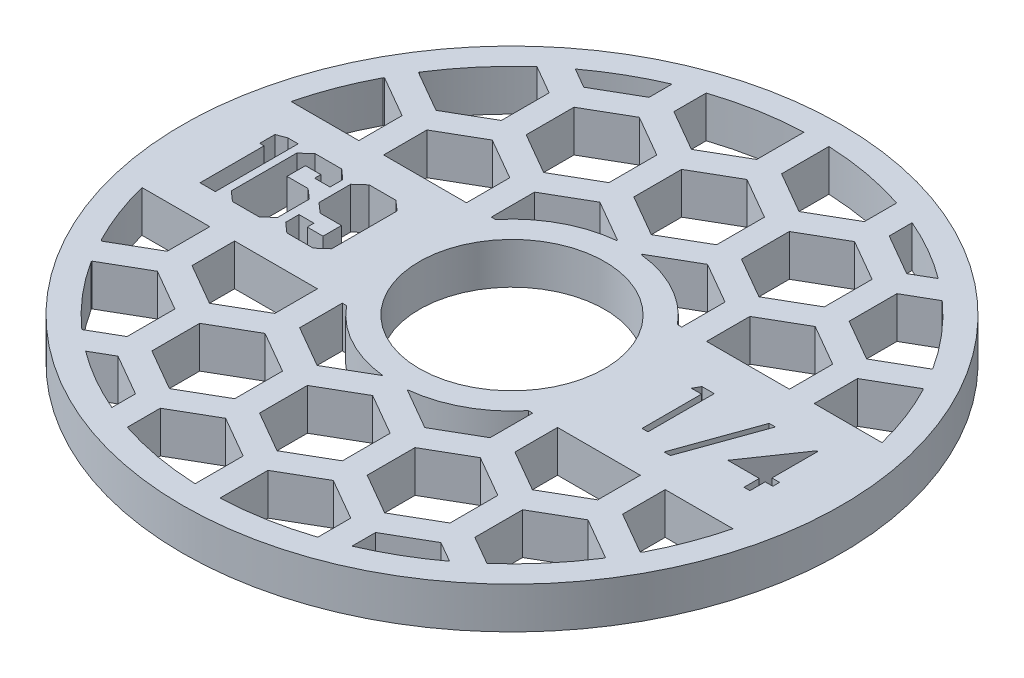
from build123d import *

# Parameters (mm, degrees)
SKETCH1_R               = 50.546
SKETCH1_R_2             = 14.224
BOSS_EXTRUDE1_DEPTH     = 6.35
CUT_EXTRUDE1_DEPTH      = 1
CUT_EXTRUDE1_DEPTH_BACK = 7.35
CUT_EXTRUDE2_DEPTH      = 1
CUT_EXTRUDE2_DEPTH_BACK = 7.35


with BuildPart() as part:
    # Sketch1 → Boss-Extrude1 (new body)
    with BuildSketch(Plane(origin=(0, 0, 0), x_dir=(1, 0, 0), z_dir=(0, 1, 0))):
        Circle(SKETCH1_R)
        Circle(SKETCH1_R_2, mode=Mode.SUBTRACT)
    extrude(amount=BOSS_EXTRUDE1_DEPTH)

    # Sketch2 → Cut-Extrude1 (cut, two sides)
    with BuildSketch(Plane(origin=(0, 6.35, 0), x_dir=(1, 0, 0), z_dir=(0, 1, 0))) as cut_extrude1_sk:
        Polygon((-22.636037344, -5.022991324), (-24.137904564, -6.35), (-28.181208978, -6.35), (-29.68547152, -5.022991324), (-29.68547152, -2.979781215), (-27.397938514, -2.979781215), (-27.397938514, -4.004979253), (-24.978662769, -4.004979253), (-24.978662769, -1.176103357), (-28.253068653, -1.176103357), (-29.750145228, 0.150905319), (-29.750145228, 5.015805356), (-28.253068653, 6.35), (-24.154671822, 6.35), (-22.636037344, 5.008619389), align=None)
        Polygon((-30.945411166, -5.022991324), (-32.449673708, -6.35), (-36.524117314, -6.35), (-38.028379857, -5.022991324), (-38.028379857, 5.015805356), (-36.540884572, 6.35), (-32.473626933, 6.35), (-30.969364391, 5.015805356), (-30.969364391, 3.05164089), (-33.321571105, 3.05164089), (-33.321571105, 4.004979253), (-35.68335911, 4.004979253), (-35.68335911, 1.176103357), (-32.449673708, 1.176103357), (-30.945411166, -0.141324029), align=None)
        Polygon((-39.151786118, -6.35), (-41.496806865, -6.35), (-41.496806865, 3.463636364), (-42.167497171, 3.463636364), (-42.167497171, 5.808657111), (-40.720722369, 6.35), (-39.151786118, 6.35), align=None)
        Polygon((24.058766026, 5.08), (25.937307692, 5.08), (25.937307692, -5.08), (25.025512821, -5.08), (25.025512821, 4.037948718), (23.462435897, 4.037948718), align=None)
        Polygon((35.05525641, 5.340512821), (30.805641026, -6.512820513), (29.845, -6.512820513), (34.094615385, 5.340512821), align=None)
        Polygon((41.38286859, 5.340512821), (41.568076923, 5.340512821), (41.568076923, -1.693333333), (42.740384615, -1.693333333), (42.740384615, -2.735384615), (41.568076923, -2.735384615), (41.568076923, -5.08), (40.656282051, -5.08), (40.656282051, -2.735384615), (35.836794872, -2.735384615), align=None)
    extrude(amount=CUT_EXTRUDE1_DEPTH, mode=Mode.SUBTRACT)
    extrude(cut_extrude1_sk.sketch, amount=-CUT_EXTRUDE1_DEPTH_BACK, mode=Mode.SUBTRACT)

    # Sketch3 → Cut-Extrude2 (cut, two sides)
    with BuildSketch(Plane(origin=(0, 6.35, 0), x_dir=(1, 0, 0), z_dir=(0, 1, 0))) as cut_extrude2_sk:
        with BuildLine():
            Line((-45.316760652, 11.43), (-34.925, 11.43))
            Line((-34.925, 11.43), (-34.925, 18.070094793))
            Line((-34.925, 18.070094793), (-41.275, 21.736269002))
            Line((-41.275, 21.736269002), (-41.416615017, 21.654507534))
            ThreePointArc((-41.416615017, 21.654507534), (-43.666975534, 16.656798723), (-45.316760652, 11.43))
        make_face()
        Polygon((-31.115, 11.43), (-18.415, 11.43), (-18.415, 18.070094793), (-24.765, 21.736269002), (-31.115, 18.070094793), align=None)
        with BuildLine():
            ThreePointArc((-31.072970625, 34.910230485), (-35.555600159, 30.332375333), (-39.37, 25.184455444))
            Line((-39.37, 25.184455444), (-39.37, 25.035825791))
            Line((-39.37, 25.035825791), (-33.02, 21.369651581))
            Line((-33.02, 21.369651581), (-26.67, 25.035825791))
            Line((-26.67, 25.035825791), (-26.67, 32.368174209))
            Line((-26.67, 32.368174209), (-31.072970625, 34.910230485))
        make_face()
        with BuildLine():
            ThreePointArc((-18.415, 42.955109952), (-23.281499402, 40.524381323), (-27.832591826, 37.544647132))
            Line((-27.832591826, 37.544647132), (-24.765, 35.773572165))
            Line((-24.765, 35.773572165), (-18.415, 39.439746374))
            Line((-18.415, 39.439746374), (-18.415, 42.955109952))
        make_face()
        Polygon((-22.86, 32.368174209), (-22.86, 25.035825791), (-16.51, 21.369651581), (-10.16, 25.035825791), (-10.16, 32.368174209), (-16.51, 36.034348419), align=None)
        with BuildLine():
            ThreePointArc((-1.905, 46.697159132), (-8.334842466, 45.986781765), (-14.605, 44.395356413))
            Line((-14.605, 44.395356413), (-14.605, 39.439746374))
            Line((-14.605, 39.439746374), (-8.255, 35.773572165))
            Line((-8.255, 35.773572165), (-1.905, 39.439746374))
            Line((-1.905, 39.439746374), (-1.905, 46.697159132))
        make_face()
        Polygon((-6.35, 32.368174209), (-6.35, 25.035825791), (0, 21.369651581), (6.35, 25.035825791), (6.35, 32.368174209), (0, 36.034348419), align=None)
        with BuildLine():
            Line((14.605, 39.439746374), (14.605, 44.395356413))
            ThreePointArc((14.605, 44.395356413), (8.334842466, 45.986781765), (1.905, 46.697159132))
            Line((1.905, 46.697159132), (1.905, 39.439746374))
            Line((1.905, 39.439746374), (8.255, 35.773572165))
            Line((8.255, 35.773572165), (14.605, 39.439746374))
        make_face()
        with BuildLine():
            Line((-14.605, 11.43), (-13.949202701, 11.43))
            ThreePointArc((-13.949202701, 11.43), (-8.568052185, 15.868636922), (-1.905, 17.933101544))
            Line((-1.905, 17.933101544), (-1.905, 18.070094793))
            Line((-1.905, 18.070094793), (-8.255, 21.736269002))
            Line((-8.255, 21.736269002), (-14.605, 18.070094793))
            Line((-14.605, 18.070094793), (-14.605, 11.43))
        make_face()
        with BuildLine():
            ThreePointArc((1.905, 17.933101544), (8.568052185, 15.868636922), (13.949202701, 11.43))
            Line((13.949202701, 11.43), (14.605, 11.43))
            Line((14.605, 11.43), (14.605, 18.070094793))
            Line((14.605, 18.070094793), (8.255, 21.736269002))
            Line((8.255, 21.736269002), (1.905, 18.070094793))
            Line((1.905, 18.070094793), (1.905, 17.933101544))
        make_face()
        Polygon((10.16, 32.368174209), (10.16, 25.035825791), (16.51, 21.369651581), (22.86, 25.035825791), (22.86, 32.368174209), (16.51, 36.034348419), align=None)
        with BuildLine():
            Line((24.765, 35.773572165), (27.832591826, 37.544647132))
            ThreePointArc((27.832591826, 37.544647132), (23.281499402, 40.524381323), (18.415, 42.955109952))
            Line((18.415, 42.955109952), (18.415, 39.439746374))
            Line((18.415, 39.439746374), (24.765, 35.773572165))
        make_face()
        with BuildLine():
            Line((39.37, 25.035825791), (39.37, 25.184455444))
            ThreePointArc((39.37, 25.184455444), (35.555600159, 30.332375333), (31.072970625, 34.910230485))
            Line((31.072970625, 34.910230485), (26.67, 32.368174209))
            Line((26.67, 32.368174209), (26.67, 25.035825791))
            Line((26.67, 25.035825791), (33.02, 21.369651581))
            Line((33.02, 21.369651581), (39.37, 25.035825791))
        make_face()
        Polygon((18.415, 18.070094793), (18.415, 11.43), (31.115, 11.43), (31.115, 18.070094793), (24.765, 21.736269002), align=None)
        with BuildLine():
            Line((34.925, 18.070094793), (34.925, 11.43))
            Line((34.925, 11.43), (45.316760652, 11.43))
            ThreePointArc((45.316760652, 11.43), (43.666975534, 16.656798723), (41.416615017, 21.654507534))
            Line((41.416615017, 21.654507534), (41.275, 21.736269002))
            Line((41.275, 21.736269002), (34.925, 18.070094793))
        make_face()
        with BuildLine():
            Line((45.316760652, -11.43), (34.925, -11.43))
            Line((34.925, -11.43), (34.925, -17.964253626))
            Line((34.925, -17.964253626), (41.275, -21.630427835))
            Line((41.275, -21.630427835), (41.495378195, -21.503192425))
            ThreePointArc((41.495378195, -21.503192425), (43.697301567, -16.577078506), (45.316760652, -11.43))
        make_face()
        Polygon((31.115, -11.43), (18.415, -11.43), (18.415, -17.964253626), (24.765, -21.630427835), (31.115, -17.964253626), align=None)
        with BuildLine():
            ThreePointArc((31.072970625, -34.910230485), (35.555600159, -30.332375333), (39.37, -25.184455444))
            Line((39.37, -25.184455444), (39.37, -25.035825791))
            Line((39.37, -25.035825791), (33.02, -21.369651581))
            Line((33.02, -21.369651581), (26.67, -25.035825791))
            Line((26.67, -25.035825791), (26.67, -32.368174209))
            Line((26.67, -32.368174209), (31.072970625, -34.910230485))
        make_face()
        Polygon((10.16, -25.035825791), (10.16, -32.368174209), (16.51, -36.034348419), (22.86, -32.368174209), (22.86, -25.035825791), (16.51, -21.369651581), align=None)
        with BuildLine():
            Line((14.605, -11.43), (13.949202701, -11.43))
            ThreePointArc((13.949202701, -11.43), (8.568052185, -15.868636922), (1.905, -17.933101544))
            Line((1.905, -17.933101544), (1.905, -17.964253626))
            Line((1.905, -17.964253626), (8.255, -21.630427835))
            Line((8.255, -21.630427835), (14.605, -17.964253626))
            Line((14.605, -17.964253626), (14.605, -11.43))
        make_face()
        Polygon((-6.35, -25.035825791), (-6.35, -32.368174209), (0, -36.034348419), (6.35, -32.368174209), (6.35, -25.035825791), (0, -21.369651581), align=None)
        with BuildLine():
            ThreePointArc((18.415, -42.955109952), (23.324782919, -40.49948392), (27.912754671, -37.485088004))
            Line((27.912754671, -37.485088004), (24.765, -35.667730998))
            Line((24.765, -35.667730998), (18.415, -39.333905207))
            Line((18.415, -39.333905207), (18.415, -42.955109952))
        make_face()
        with BuildLine():
            ThreePointArc((1.954953877, -46.69509451), (8.359438793, -45.982317026), (14.605, -44.395356413))
            Line((14.605, -44.395356413), (14.605, -39.333905207))
            Line((14.605, -39.333905207), (8.255, -35.667730998))
            Line((8.255, -35.667730998), (1.905, -39.333905207))
            Line((1.905, -39.333905207), (1.905, -46.666253626))
            Line((1.905, -46.666253626), (1.954953877, -46.69509451))
        make_face()
        with BuildLine():
            Line((-14.605, -39.333905207), (-14.605, -44.395356413))
            ThreePointArc((-14.605, -44.395356413), (-8.359438793, -45.982317026), (-1.954953877, -46.69509451))
            Line((-1.954953877, -46.69509451), (-1.905, -46.666253626))
            Line((-1.905, -46.666253626), (-1.905, -39.333905207))
            Line((-1.905, -39.333905207), (-8.255, -35.667730998))
            Line((-8.255, -35.667730998), (-14.605, -39.333905207))
        make_face()
        with BuildLine():
            Line((-24.765, -35.667730998), (-27.912754671, -37.485088004))
            ThreePointArc((-27.912754671, -37.485088004), (-23.324782919, -40.49948392), (-18.415, -42.955109952))
            Line((-18.415, -42.955109952), (-18.415, -39.333905207))
            Line((-18.415, -39.333905207), (-24.765, -35.667730998))
        make_face()
        Polygon((-22.86, -25.035825791), (-22.86, -32.368174209), (-16.51, -36.034348419), (-10.16, -32.368174209), (-10.16, -25.035825791), (-16.51, -21.369651581), align=None)
        with BuildLine():
            Line((-39.37, -25.035825791), (-39.37, -25.184455444))
            ThreePointArc((-39.37, -25.184455444), (-35.555600159, -30.332375333), (-31.072970625, -34.910230485))
            Line((-31.072970625, -34.910230485), (-26.67, -32.368174209))
            Line((-26.67, -32.368174209), (-26.67, -25.035825791))
            Line((-26.67, -25.035825791), (-33.02, -21.369651581))
            Line((-33.02, -21.369651581), (-39.37, -25.035825791))
        make_face()
        with BuildLine():
            Line((-34.925, -17.964253626), (-34.925, -11.43))
            Line((-34.925, -11.43), (-45.316760652, -11.43))
            ThreePointArc((-45.316760652, -11.43), (-43.697301567, -16.577078506), (-41.495378195, -21.503192425))
            Line((-41.495378195, -21.503192425), (-41.275, -21.630427835))
            Line((-41.275, -21.630427835), (-34.925, -17.964253626))
        make_face()
        Polygon((-18.415, -17.964253626), (-18.415, -11.43), (-31.115, -11.43), (-31.115, -17.964253626), (-24.765, -21.630427835), align=None)
        with BuildLine():
            ThreePointArc((-1.905, -17.933101544), (-8.568052185, -15.868636922), (-13.949202701, -11.43))
            Line((-13.949202701, -11.43), (-14.605, -11.43))
            Line((-14.605, -11.43), (-14.605, -17.964253626))
            Line((-14.605, -17.964253626), (-8.255, -21.630427835))
            Line((-8.255, -21.630427835), (-1.905, -17.964253626))
            Line((-1.905, -17.964253626), (-1.905, -17.933101544))
        make_face()
    extrude(amount=CUT_EXTRUDE2_DEPTH, mode=Mode.SUBTRACT)
    extrude(cut_extrude2_sk.sketch, amount=-CUT_EXTRUDE2_DEPTH_BACK, mode=Mode.SUBTRACT)


solid = part.part
